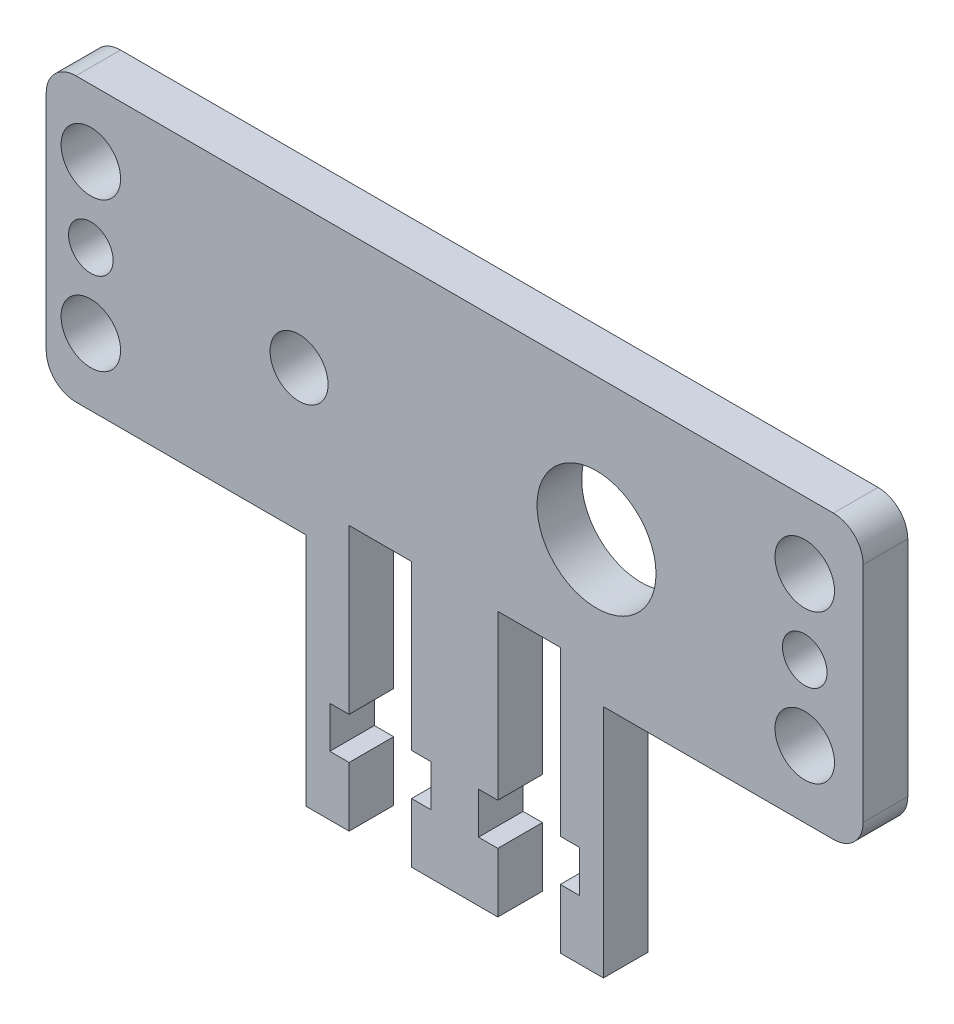
from build123d import *

# Parameters (mm, degrees)
SKETCH1_R           = 2
SKETCH1_R_2         = 4
SKETCH1_R_3         = 1.95
SKETCH1_R_4         = 1.5
BOSS_EXTRUDE1_DEPTH = 3


with BuildPart() as part:
    # Sketch1 → Boss-Extrude1 (new body)
    with BuildSketch(Plane.XY.offset(-5.551615438)):
        with BuildLine():
            Line((-25.464626351, 10.13731735), (25.464626351, 10.13731735))
            ThreePointArc((25.464626351, 10.13731735), (26.878839913, 9.551530913), (27.464626351, 8.13731735))
            Line((27.464626351, 8.13731735), (27.464626351, -6.86268265))
            ThreePointArc((27.464626351, -6.86268265), (26.878839913, -8.276896212), (25.464626351, -8.86268265))
            Line((25.464626351, -8.86268265), (10, -8.86268265))
            Line((10, -8.86268265), (10, -24.66268265))
            Line((10, -24.66268265), (7.1, -24.66268265))
            Line((7.1, -24.66268265), (7.1, -20.66268265))
            Line((7.1, -20.66268265), (8.4, -20.66268265))
            Line((8.4, -20.66268265), (8.4, -17.86268265))
            Line((8.4, -17.86268265), (7.1, -17.86268265))
            Line((7.1, -17.86268265), (7.1, -6.86268265))
            Line((7.1, -6.86268265), (2.9, -6.86268265))
            Line((2.9, -6.86268265), (2.9, -17.86268265))
            Line((2.9, -17.86268265), (1.6, -17.86268265))
            Line((1.6, -17.86268265), (1.6, -20.66268265))
            Line((1.6, -20.66268265), (2.9, -20.66268265))
            Line((2.9, -20.66268265), (2.9, -24.66268265))
            Line((2.9, -24.66268265), (0, -24.66268265))
            Line((0, -24.66268265), (-2.9, -24.66268265))
            Line((-2.9, -24.66268265), (-2.9, -20.66268265))
            Line((-2.9, -20.66268265), (-1.6, -20.66268265))
            Line((-1.6, -20.66268265), (-1.6, -17.86268265))
            Line((-1.6, -17.86268265), (-2.9, -17.86268265))
            Line((-2.9, -17.86268265), (-2.9, -6.86268265))
            Line((-2.9, -6.86268265), (-7.1, -6.86268265))
            Line((-7.1, -6.86268265), (-7.1, -17.86268265))
            Line((-7.1, -17.86268265), (-8.4, -17.86268265))
            Line((-8.4, -17.86268265), (-8.4, -20.66268265))
            Line((-8.4, -20.66268265), (-7.1, -20.66268265))
            Line((-7.1, -20.66268265), (-7.1, -24.66268265))
            Line((-7.1, -24.66268265), (-10, -24.66268265))
            Line((-10, -24.66268265), (-10, -8.86268265))
            Line((-10, -8.86268265), (-25.464626351, -8.86268265))
            ThreePointArc((-25.464626351, -8.86268265), (-26.878839913, -8.276896212), (-27.464626351, -6.86268265))
            Line((-27.464626351, -6.86268265), (-27.464626351, 8.13731735))
            ThreePointArc((-27.464626351, 8.13731735), (-26.878839913, 9.551530913), (-25.464626351, 10.13731735))
        make_face()
        with Locations((-24.464626351, 5.63731735)):
            Circle(SKETCH1_R, mode=Mode.SUBTRACT)
        with Locations((-24.464626351, -4.36268265)):
            Circle(SKETCH1_R, mode=Mode.SUBTRACT)
        with Locations((23.535373649, -4.36268265)):
            Circle(SKETCH1_R, mode=Mode.SUBTRACT)
        with Locations((23.535373649, 5.63731735)):
            Circle(SKETCH1_R, mode=Mode.SUBTRACT)
        with Locations((9.535373649, 0.63731735)):
            Circle(SKETCH1_R_2, mode=Mode.SUBTRACT)
        with Locations((-10.464626351, 0.63731735)):
            Circle(SKETCH1_R_3, mode=Mode.SUBTRACT)
        with Locations((-24.464626351, 0.63731735)):
            Circle(SKETCH1_R_4, mode=Mode.SUBTRACT)
        with Locations((23.535373649, 0.63731735)):
            Circle(SKETCH1_R_4, mode=Mode.SUBTRACT)
    extrude(amount=BOSS_EXTRUDE1_DEPTH)


solid = part.part
